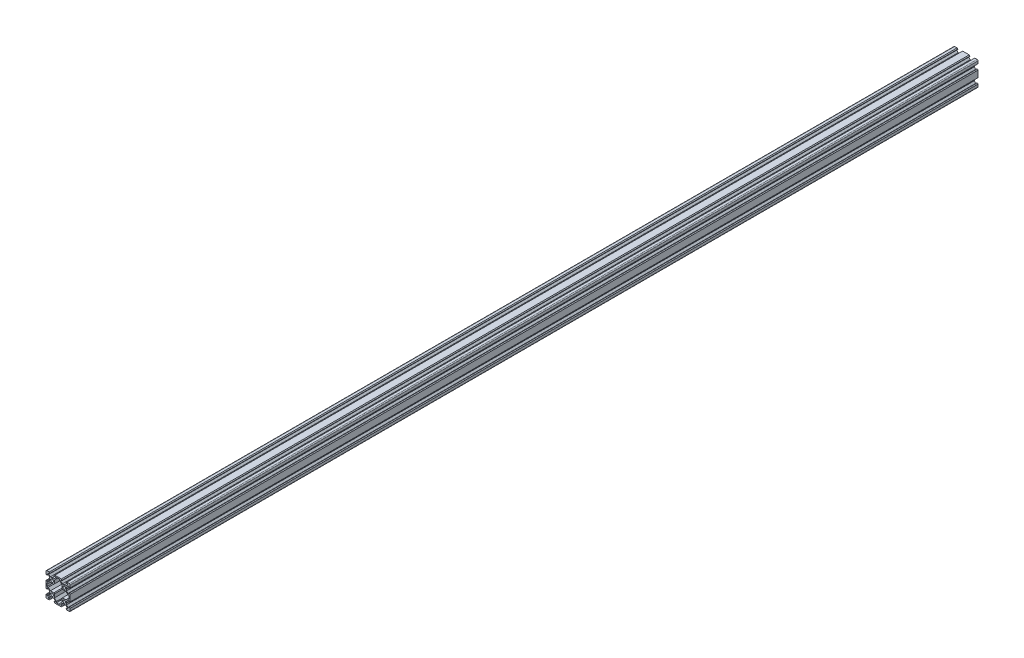
from build123d import *

# Parameters (mm, degrees)
SKETCH1_R           = 2.3
BOSS_EXTRUDE1_DEPTH = 1500


with BuildPart() as part:
    # Sketch1 → Boss-Extrude1 (new body)
    with BuildSketch(Plane.XY):
        with BuildLine():
            Line((14.58, -20), (18.5, -20))
            ThreePointArc((18.5, -20), (19.560660172, -19.560660172), (20, -18.5))
            Line((20, -18.5), (20, -14.58))
            Line((20, -14.58), (18.815, -13.395))
            Line((18.815, -13.395), (18.2, -13.395))
            Line((18.2, -13.395), (18.2, -15.5))
            Line((18.2, -15.5), (16.560660172, -15.5))
            Line((16.560660172, -15.5), (13.9, -12.839339828))
            Line((13.9, -12.839339828), (13.9, -10.21))
            Line((13.9, -10.21), (13.69, -10))
            Line((13.69, -10), (13.9, -9.79))
            Line((13.9, -9.79), (13.9, -7.160660172))
            Line((13.9, -7.160660172), (16.560660172, -4.5))
            Line((16.560660172, -4.5), (18.2, -4.5))
            Line((18.2, -4.5), (18.2, -6.605))
            Line((18.2, -6.605), (18.815, -6.605))
            Line((18.815, -6.605), (20, -5.42))
            Line((20, -5.42), (20, 5.42))
            Line((20, 5.42), (18.815, 6.605))
            Line((18.815, 6.605), (18.2, 6.605))
            Line((18.2, 6.605), (18.2, 4.5))
            Line((18.2, 4.5), (16.560660172, 4.5))
            Line((16.560660172, 4.5), (13.9, 7.160660172))
            Line((13.9, 7.160660172), (13.9, 9.79))
            Line((13.9, 9.79), (13.69, 10))
            Line((13.69, 10), (13.9, 10.21))
            Line((13.9, 10.21), (13.9, 12.839339828))
            Line((13.9, 12.839339828), (16.560660172, 15.5))
            Line((16.560660172, 15.5), (18.2, 15.5))
            Line((18.2, 15.5), (18.2, 13.395))
            Line((18.2, 13.395), (18.815, 13.395))
            Line((18.815, 13.395), (20, 14.58))
            Line((20, 14.58), (20, 18.5))
            ThreePointArc((20, 18.5), (19.560660172, 19.560660172), (18.5, 20))
            Line((18.5, 20), (14.58, 20))
            Line((14.58, 20), (13.395, 18.815))
            Line((13.395, 18.815), (13.395, 18.2))
            Line((13.395, 18.2), (15.5, 18.2))
            Line((15.5, 18.2), (15.5, 16.560660172))
            Line((15.5, 16.560660172), (12.839339828, 13.9))
            Line((12.839339828, 13.9), (10.21, 13.9))
            Line((10.21, 13.9), (10, 13.69))
            Line((10, 13.69), (9.79, 13.9))
            Line((9.79, 13.9), (7.160660172, 13.9))
            Line((7.160660172, 13.9), (4.5, 16.560660172))
            Line((4.5, 16.560660172), (4.5, 18.2))
            Line((4.5, 18.2), (6.605, 18.2))
            Line((6.605, 18.2), (6.605, 18.815))
            Line((6.605, 18.815), (5.42, 20))
            Line((5.42, 20), (-5.42, 20))
            Line((-5.42, 20), (-6.605, 18.815))
            Line((-6.605, 18.815), (-6.605, 18.2))
            Line((-6.605, 18.2), (-4.5, 18.2))
            Line((-4.5, 18.2), (-4.5, 16.560660172))
            Line((-4.5, 16.560660172), (-7.160660172, 13.9))
            Line((-7.160660172, 13.9), (-9.79, 13.9))
            Line((-9.79, 13.9), (-10, 13.69))
            Line((-10, 13.69), (-10.21, 13.9))
            Line((-10.21, 13.9), (-12.839339828, 13.9))
            Line((-12.839339828, 13.9), (-15.5, 16.560660172))
            Line((-15.5, 16.560660172), (-15.5, 18.2))
            Line((-15.5, 18.2), (-13.395, 18.2))
            Line((-13.395, 18.2), (-13.395, 18.815))
            Line((-13.395, 18.815), (-14.58, 20))
            Line((-14.58, 20), (-18.5, 20))
            ThreePointArc((-18.5, 20), (-19.560660172, 19.560660172), (-20, 18.5))
            Line((-20, 18.5), (-20, 14.58))
            Line((-20, 14.58), (-18.815, 13.395))
            Line((-18.815, 13.395), (-18.2, 13.395))
            Line((-18.2, 13.395), (-18.2, 15.5))
            Line((-18.2, 15.5), (-16.560660172, 15.5))
            Line((-16.560660172, 15.5), (-13.9, 12.839339828))
            Line((-13.9, 12.839339828), (-13.9, 10.21))
            Line((-13.9, 10.21), (-13.69, 10))
            Line((-13.69, 10), (-13.9, 9.79))
            Line((-13.9, 9.79), (-13.9, 7.160660172))
            Line((-13.9, 7.160660172), (-16.560660172, 4.5))
            Line((-16.560660172, 4.5), (-18.2, 4.5))
            Line((-18.2, 4.5), (-18.2, 6.605))
            Line((-18.2, 6.605), (-18.815, 6.605))
            Line((-18.815, 6.605), (-20, 5.42))
            Line((-20, 5.42), (-20, -5.42))
            Line((-20, -5.42), (-18.815, -6.605))
            Line((-18.815, -6.605), (-18.2, -6.605))
            Line((-18.2, -6.605), (-18.2, -4.5))
            Line((-18.2, -4.5), (-16.560660172, -4.5))
            Line((-16.560660172, -4.5), (-13.9, -7.160660172))
            Line((-13.9, -7.160660172), (-13.9, -9.79))
            Line((-13.9, -9.79), (-13.69, -10))
            Line((-13.69, -10), (-13.9, -10.21))
            Line((-13.9, -10.21), (-13.9, -12.839339828))
            Line((-13.9, -12.839339828), (-16.560660172, -15.5))
            Line((-16.560660172, -15.5), (-18.2, -15.5))
            Line((-18.2, -15.5), (-18.2, -13.395))
            Line((-18.2, -13.395), (-18.815, -13.395))
            Line((-18.815, -13.395), (-20, -14.58))
            Line((-20, -14.58), (-20, -18.5))
            ThreePointArc((-20, -18.5), (-19.560660172, -19.560660172), (-18.5, -20))
            Line((-18.5, -20), (-14.58, -20))
            Line((-14.58, -20), (-13.395, -18.815))
            Line((-13.395, -18.815), (-13.395, -18.2))
            Line((-13.395, -18.2), (-15.5, -18.2))
            Line((-15.5, -18.2), (-15.5, -16.560660172))
            Line((-15.5, -16.560660172), (-12.839339828, -13.9))
            Line((-12.839339828, -13.9), (-10.21, -13.9))
            Line((-10.21, -13.9), (-10, -13.69))
            Line((-10, -13.69), (-9.79, -13.9))
            Line((-9.79, -13.9), (-7.160660172, -13.9))
            Line((-7.160660172, -13.9), (-4.5, -16.560660172))
            Line((-4.5, -16.560660172), (-4.5, -18.2))
            Line((-4.5, -18.2), (-6.605, -18.2))
            Line((-6.605, -18.2), (-6.605, -18.815))
            Line((-6.605, -18.815), (-5.42, -20))
            Line((-5.42, -20), (5.42, -20))
            Line((5.42, -20), (6.605, -18.815))
            Line((6.605, -18.815), (6.605, -18.2))
            Line((6.605, -18.2), (4.5, -18.2))
            Line((4.5, -18.2), (4.5, -16.560660172))
            Line((4.5, -16.560660172), (7.160660172, -13.9))
            Line((7.160660172, -13.9), (9.79, -13.9))
            Line((9.79, -13.9), (10, -13.69))
            Line((10, -13.69), (10.21, -13.9))
            Line((10.21, -13.9), (12.839339828, -13.9))
            Line((12.839339828, -13.9), (15.5, -16.560660172))
            Line((15.5, -16.560660172), (15.5, -18.2))
            Line((15.5, -18.2), (13.395, -18.2))
            Line((13.395, -18.2), (13.395, -18.815))
            Line((13.395, -18.815), (14.58, -20))
        make_face()
        with Locations((-10, -10)):
            Circle(SKETCH1_R, mode=Mode.SUBTRACT)
        with Locations((10, -10)):
            Circle(SKETCH1_R, mode=Mode.SUBTRACT)
        Polygon((-16.239339828, -2.7), (-18.2, -2.7), (-18.2, 2.7), (-16.239339828, 2.7), (-12.839339828, 6.1), (-7.160660172, 6.1), (-6.1, 7.160660172), (-6.1, 12.839339828), (-2.7, 16.239339828), (-2.7, 18.2), (2.7, 18.2), (2.7, 16.239339828), (6.1, 12.839339828), (6.1, 7.160660172), (7.160660172, 6.1), (12.839339828, 6.1), (16.239339828, 2.7), (18.2, 2.7), (18.2, -2.7), (16.239339828, -2.7), (12.839339828, -6.1), (7.160660172, -6.1), (6.1, -7.160660172), (6.1, -12.839339828), (2.7, -16.239339828), (2.7, -18.2), (-2.7, -18.2), (-2.7, -16.239339828), (-6.1, -12.839339828), (-6.1, -7.160660172), (-7.160660172, -6.1), (-12.839339828, -6.1), align=None, mode=Mode.SUBTRACT)
        with Locations((-10, 10)):
            Circle(SKETCH1_R, mode=Mode.SUBTRACT)
        with Locations((10, 10)):
            Circle(SKETCH1_R, mode=Mode.SUBTRACT)
    extrude(amount=BOSS_EXTRUDE1_DEPTH)


solid = part.part
